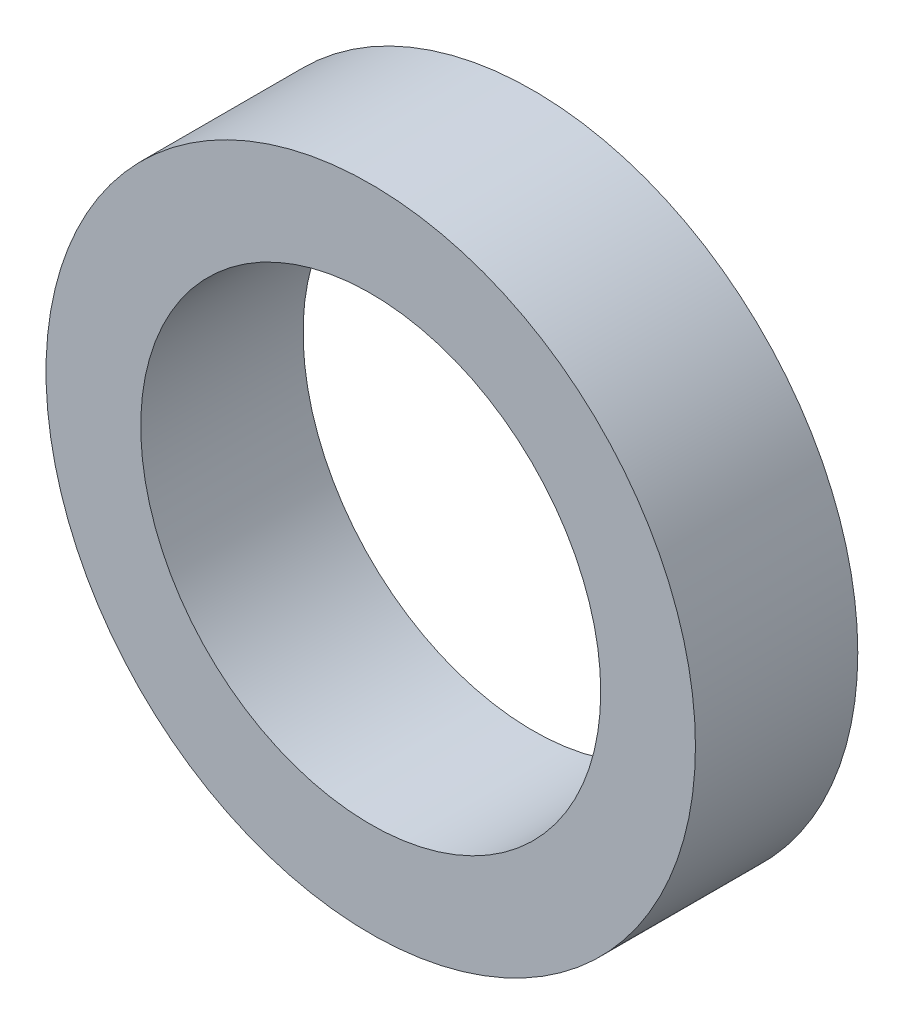
from build123d import *

# Parameters (mm, degrees)
ESQUISSE1_R        = 6
ESQUISSE1_R_2      = 4.25
BOSS_EXTRU_1_DEPTH = 3


with BuildPart() as part:
    # Esquisse1 → Boss.-Extru.1 (new body)
    with BuildSketch(Plane.XY):
        Circle(ESQUISSE1_R)
        Circle(ESQUISSE1_R_2, mode=Mode.SUBTRACT)
    extrude(amount=BOSS_EXTRU_1_DEPTH)


solid = part.part
